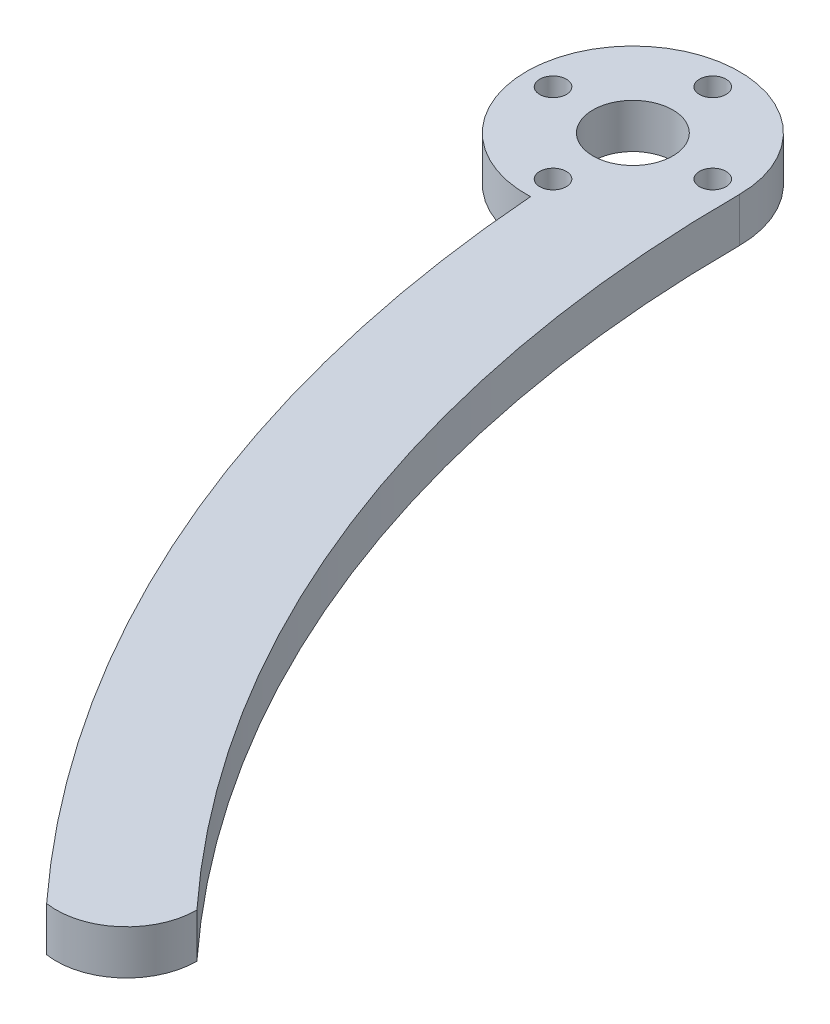
from build123d import *

# Parameters (mm, degrees)
ESQUISSE1_R             = 4.5
BOSS_EXTRU_1_DEPTH      = 5
ESQUISSE2_R             = 1.5
ENL_V_MAT_EXTRU_1_DEPTH = 5


with BuildPart() as part:
    # Esquisse1 → Boss.-Extru.1 (new body)
    with BuildSketch(Plane(origin=(0, 0, 0), x_dir=(1, 0, 0), z_dir=(0, 1, 0))):
        with BuildLine():
            ThreePointArc((-148, 0), (-168.642916175, 8.324662155), (-159.55, -11.991559532))
            ThreePointArc((-159.55, -11.991559532), (-146.800083184, -63.637532772), (-117.822638991, -108.24890642))
            ThreePointArc((-117.822638991, -108.24890642), (-111.47655915, -106.418874078), (-108.723180083, -100.415487414))
            ThreePointArc((-108.723180083, -100.415487414), (-137.831474367, -53.911823136), (-148, 0))
        make_face()
        with Locations((-160, 0)):
            Circle(ESQUISSE1_R, mode=Mode.SUBTRACT)
    extrude(amount=BOSS_EXTRU_1_DEPTH)

    # Esquisse2 → Enlèv. mat.-Extru.1 (cut)
    with BuildSketch(Plane(origin=(0, 5, 0), x_dir=(1, 0, 0), z_dir=(0, 1, 0))):
        with Locations((-151, 0)):
            Circle(ESQUISSE2_R)
        with Locations((-160, -9)):
            Circle(ESQUISSE2_R)
        with Locations((-169, 0)):
            Circle(ESQUISSE2_R)
        with Locations((-160, 9)):
            Circle(ESQUISSE2_R)
    extrude(amount=-ENL_V_MAT_EXTRU_1_DEPTH, mode=Mode.SUBTRACT)


solid = part.part
